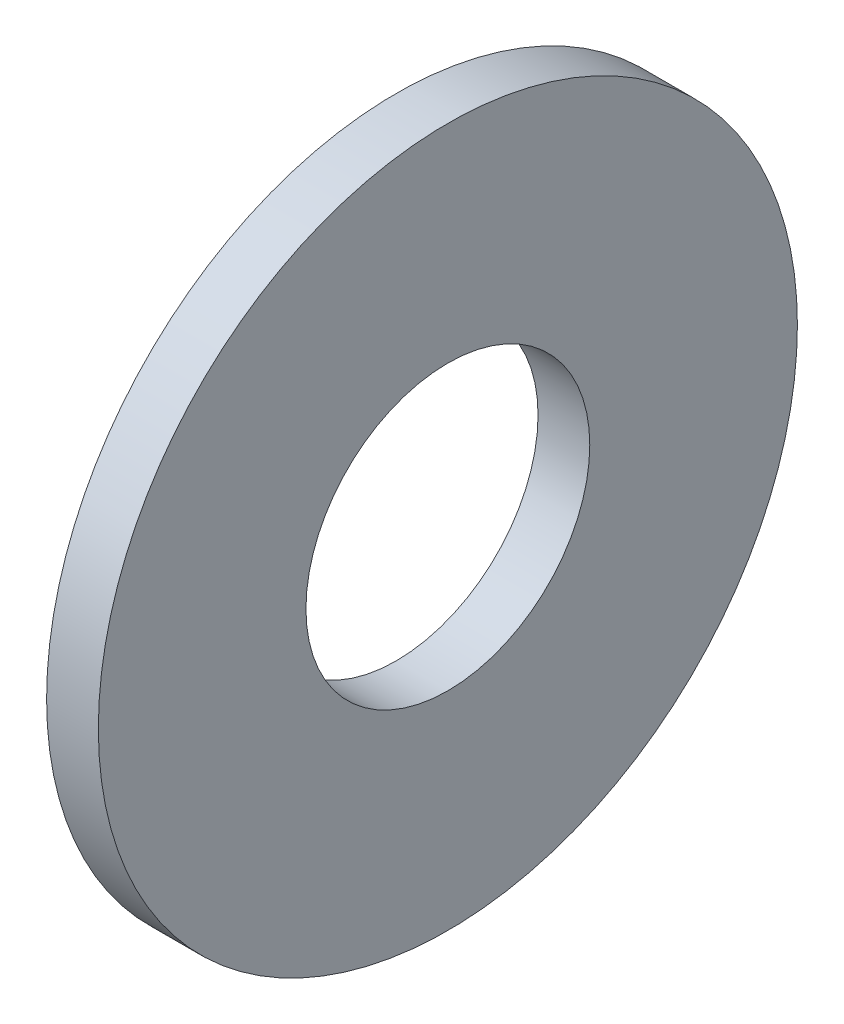
from build123d import *

# Parameters (mm, degrees)
SKETCH1_R           = 12.7
SKETCH1_R_2         = 5.1562
BOSS_EXTRUDE1_DEPTH = 1.8796


with BuildPart() as part:
    # Sketch1 → Boss-Extrude1 (new body)
    with BuildSketch(Plane(origin=(0, 0, 0), x_dir=(0, 0, -1), z_dir=(1, 0, 0))):
        Circle(SKETCH1_R)
        Circle(SKETCH1_R_2, mode=Mode.SUBTRACT)
    extrude(amount=BOSS_EXTRUDE1_DEPTH)


solid = part.part
